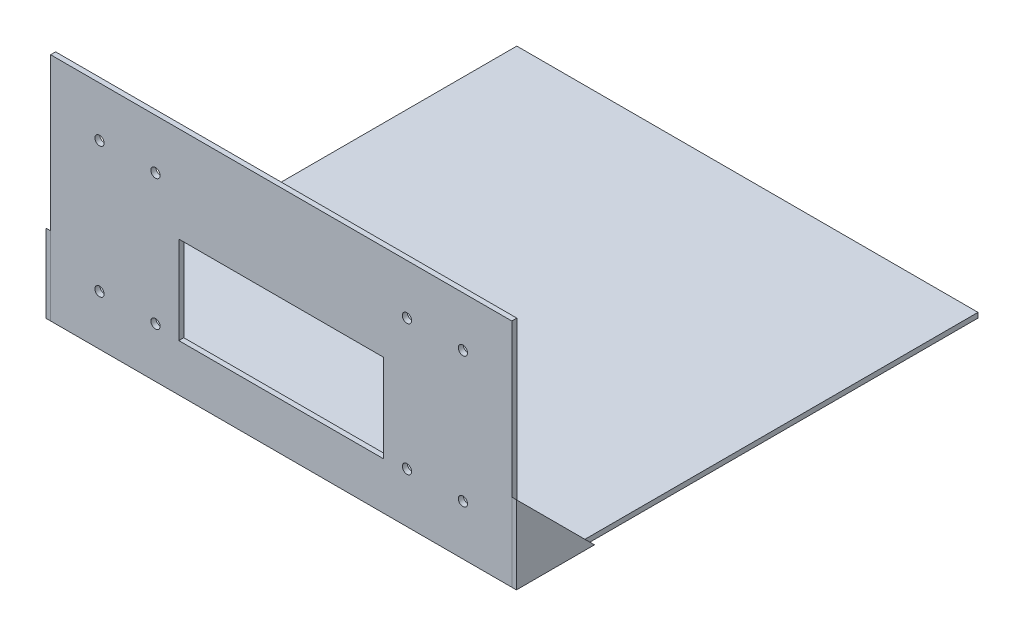
from build123d import *

# Parameters (mm, degrees)
SKETCH1_W           = 300
SKETCH1_H           = 300
BOSS_EXTRUDE1_DEPTH = 3.25
SKETCH2_W           = 300
SKETCH2_H           = 150
BOSS_EXTRUDE2_DEPTH = 3.25
SKETCH3_W           = 133.232581151
SKETCH3_H           = 57.198779066
CUT_EXTRUDE1_DEPTH  = 3.25
SKETCH4_R           = 3
CUT_EXTRUDE2_DEPTH  = 21.75
BOSS_EXTRUDE3_DEPTH = 3


with BuildPart() as part:
    # Sketch1 → Boss-Extrude1 (new body)
    with BuildSketch(Plane(origin=(0, 0, 0), x_dir=(1, 0, 0), z_dir=(0, 1, 0))):
        Rectangle(SKETCH1_W, SKETCH1_H)
    extrude(amount=BOSS_EXTRUDE1_DEPTH)


with BuildPart() as body_2:
    # Sketch2 → Boss-Extrude2 (new body)
    with BuildSketch(Plane.XY.offset(150)):
        with Locations((0, 75)):
            Rectangle(SKETCH2_W, SKETCH2_H)
    extrude(amount=BOSS_EXTRUDE2_DEPTH)

    # Sketch3 → Cut-Extrude1 (cut)
    with BuildSketch(Plane.XY.offset(153.25)):
        with Locations((-1e-09, 59.249991748)):
            Rectangle(SKETCH3_W, SKETCH3_H)
    extrude(amount=-CUT_EXTRUDE1_DEPTH, mode=Mode.SUBTRACT)

    # Sketch4 → Cut-Extrude2 (cut, through all)
    with BuildSketch(Plane.XY.offset(132.5)):
        with Locations((81.79658804, 117.567539588)):
            Circle(SKETCH4_R)
        with Locations((118.20341196, 117.567539588)):
            Circle(SKETCH4_R)
        with Locations((118.20341196, 32.567539588)):
            Circle(SKETCH4_R)
        with Locations((81.79658804, 32.567539588)):
            Circle(SKETCH4_R)
        with Locations((-81.79658804, 32.567539588)):
            Circle(SKETCH4_R)
        with Locations((-118.20341196, 32.567539588)):
            Circle(SKETCH4_R)
        with Locations((-118.20341196, 117.567539588)):
            Circle(SKETCH4_R)
        with Locations((-81.79658804, 117.567539588)):
            Circle(SKETCH4_R)
    extrude(amount=CUT_EXTRUDE2_DEPTH, mode=Mode.SUBTRACT)


with BuildPart() as body_3:
    # Sketch5 → Boss-Extrude3 (new body)
    with BuildSketch(Plane(origin=(150, 0, 0), x_dir=(0, 0, -1), z_dir=(1, 0, 0))):
        Polygon((-153.25, 0), (-153.25, 50.8), (-102.45, 0), align=None)
    extrude(amount=BOSS_EXTRUDE3_DEPTH)


with BuildPart() as body_4:
    # Mirror1: mirrored copy
    add(body_3.part.mirror(Plane(origin=(0, 0, 0), x_dir=(0, 0, 1), z_dir=(1, 0, 0))))


solid = Compound([part.part, body_2.part, body_3.part, body_4.part])
